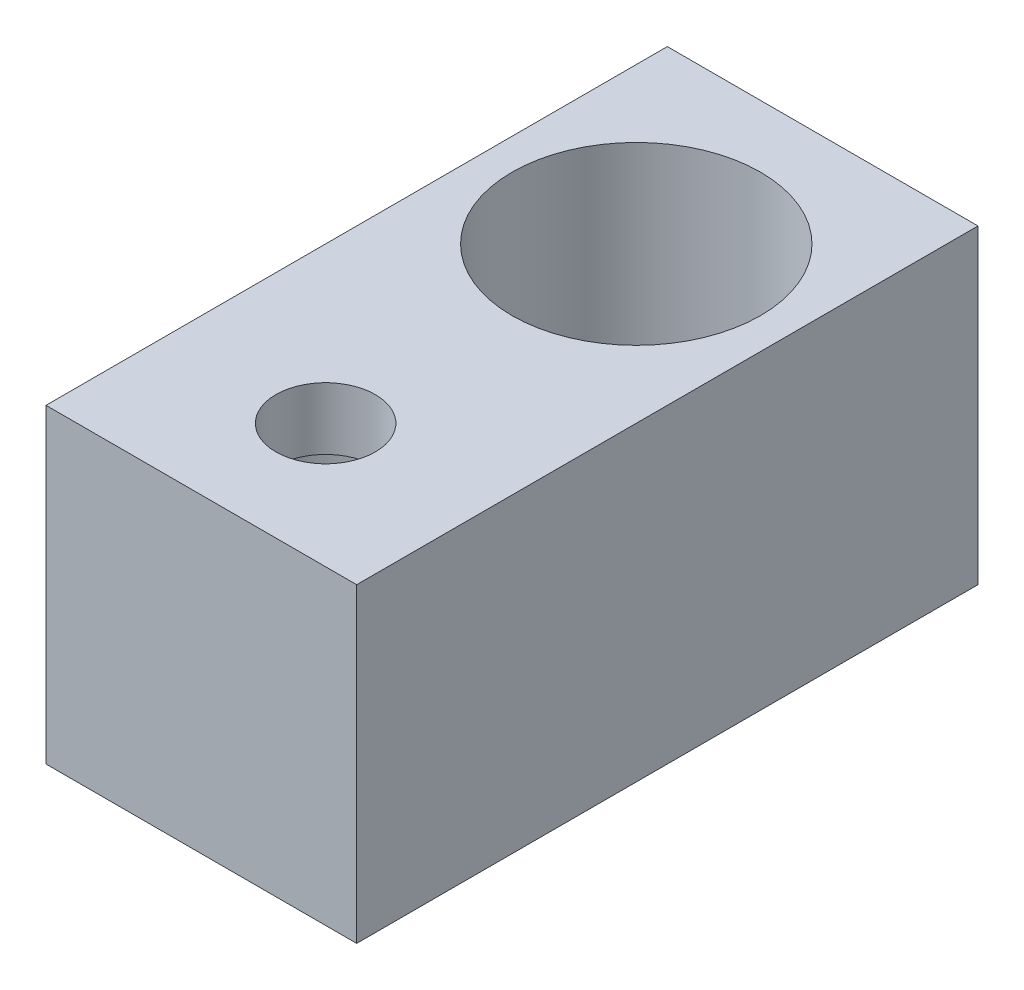
from build123d import *

# Parameters (mm, degrees)
SKETCH1_W           = 10
SKETCH1_H           = 20
SKETCH1_R           = 4
SKETCH1_R_2         = 1.6
BOSS_EXTRUDE1_DEPTH = 10
SKETCH2_R           = 3
CUT_EXTRUDE1_DEPTH  = 8


with BuildPart() as part:
    # Sketch1 → Boss-Extrude1 (new body)
    with BuildSketch(Plane(origin=(0, 0, 0), x_dir=(1, 0, 0), z_dir=(0, 1, 0))):
        with Locations((5, -10)):
            Rectangle(SKETCH1_W, SKETCH1_H)
        with Locations((5, -6)):
            Circle(SKETCH1_R, mode=Mode.SUBTRACT)
        with Locations((5, -16)):
            Circle(SKETCH1_R_2, mode=Mode.SUBTRACT)
    extrude(amount=BOSS_EXTRUDE1_DEPTH)

    # Sketch2 → Cut-Extrude1 (cut)
    with BuildSketch(Plane.XZ):
        with Locations((5, 16)):
            Circle(SKETCH2_R)
    extrude(amount=-CUT_EXTRUDE1_DEPTH, mode=Mode.SUBTRACT)


solid = part.part
